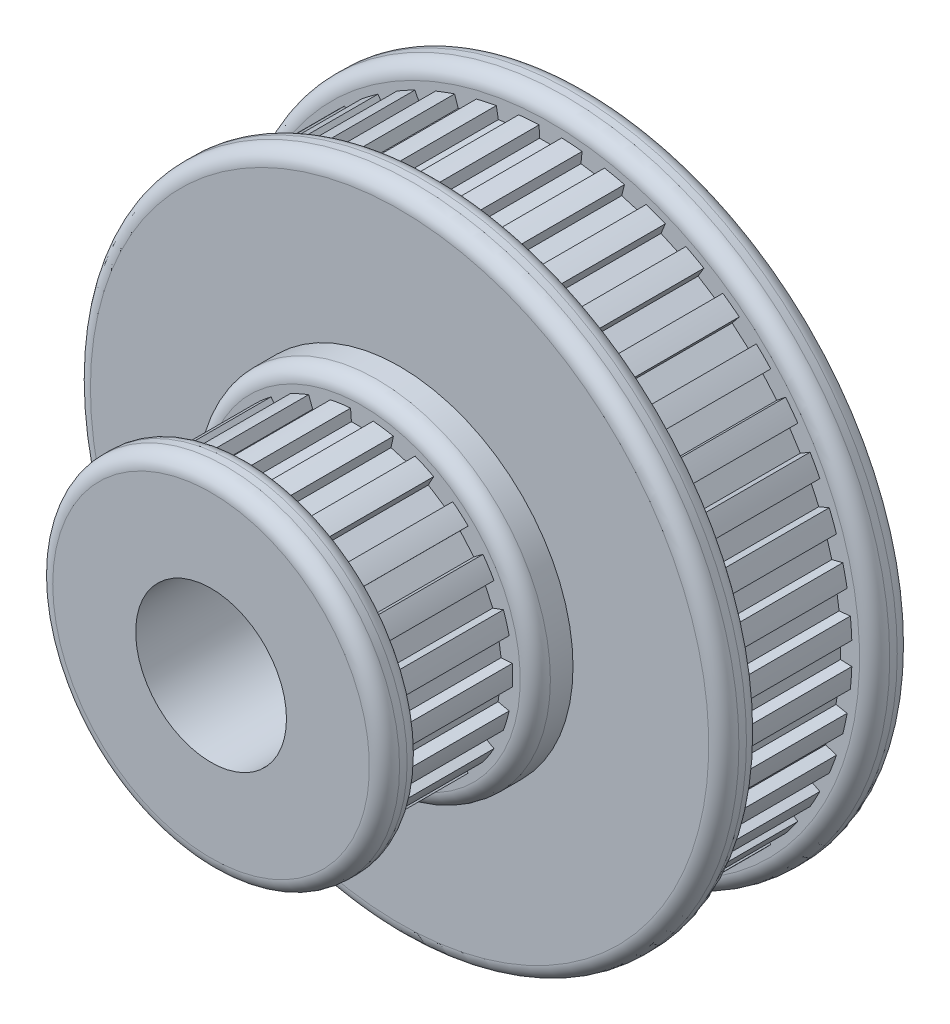
from build123d import *

# Parameters (mm, degrees)
CUT_EXTRUDE1_DEPTH = 15
CIRPATTERN1_COUNT  = 22
CUT_EXTRUDE2_DEPTH = 15
CIRPATTERN2_COUNT  = 44
FILLET1_R          = 2
FILLET2_R          = 2


with BuildPart() as part:
    # Sketch1 → Revolve1 (revolve)
    with BuildSketch(Plane(origin=(0, 0, 0), x_dir=(0, 0, -1), z_dir=(1, 0, 0))):
        Polygon((0, 10), (50, 10), (50, 43), (45, 43), (45, 40), (30, 40), (30, 43), (25, 43), (25, 23), (20, 23), (20, 20), (5, 20), (5, 23), (0, 23), align=None)
    revolve(axis=Axis((0, 0, 0), (0, 0, -1)))

    # Sketch2 → Cut-Extrude1 (cut)
    with BuildSketch(Plane.XY.offset(-20)):
        with BuildLine():
            Line((-1.387182253, 18.443670675), (1.387182253, 18.443670675))
            Line((1.387182253, 18.443670675), (1.5, 19.943670675))
            ThreePointArc((1.5, 19.943670675), (0, 20), (-1.5, 19.943670675))
            Line((-1.5, 19.943670675), (-1.387182253, 18.443670675))
        make_face()
    cut_extrude1 = extrude(amount=CUT_EXTRUDE1_DEPTH, mode=Mode.SUBTRACT)

    # CirPattern1: Cut-Extrude1 ×22 about axis
    cirpattern1_axis = Axis((0, 0, 0), (0, 0, 1))
    for i in range(1, CIRPATTERN1_COUNT):
        add(cut_extrude1.rotate(cirpattern1_axis, i * 360 / CIRPATTERN1_COUNT), mode=Mode.SUBTRACT)

    # Sketch3 → Cut-Extrude2 (cut)
    with BuildSketch(Plane.XY.offset(-45)):
        with BuildLine():
            Line((-1.443710407, 38.471865105), (1.443710407, 38.471865105))
            Line((1.443710407, 38.471865105), (1.5, 39.971865105))
            ThreePointArc((1.5, 39.971865105), (0, 40), (-1.5, 39.971865105))
            Line((-1.5, 39.971865105), (-1.443710407, 38.471865105))
        make_face()
    cut_extrude2 = extrude(amount=CUT_EXTRUDE2_DEPTH, mode=Mode.SUBTRACT)

    # CirPattern2: Cut-Extrude2 ×44 about axis
    cirpattern2_axis = Axis((0, 0, 0), (0, 0, 1))
    for i in range(1, CIRPATTERN2_COUNT):
        add(cut_extrude2.rotate(cirpattern2_axis, i * 360 / CIRPATTERN2_COUNT), mode=Mode.SUBTRACT)

    # Sketch5 → Cut-Revolve4 (revolve, cut)
    with BuildSketch(Plane(origin=(0, 0, 0), x_dir=(0, 0, -1), z_dir=(1, 0, 0))):
        Polygon((50, 35.5), (50, 21), (40, 26.773502692), (40, 29.726497308), align=None)
    revolve(axis=Axis((0, 0, 0), (0, 0, -1)), mode=Mode.SUBTRACT)

    # Fillet1
    fillet1_edges = [part.edges().sort_by_distance(p)[0] for p in [
        (0, -23, 0),
        (0, -23, -5),
        (0, -23, -20),
        (0, -43, -25),
        (0, -43, -30),
        (0, -43, -45),
        (0, -43, -50),
    ]]
    fillet(fillet1_edges, radius=FILLET1_R)

    # Fillet2
    fillet2_edges = [part.edges().sort_by_distance(p)[0] for p in [
        (0, -35.5, -50),
        (0, -21, -50),
        (0, -26.773502692, -40),
        (0, -29.726497308, -40),
    ]]
    fillet(fillet2_edges, radius=FILLET2_R)


solid = part.part
